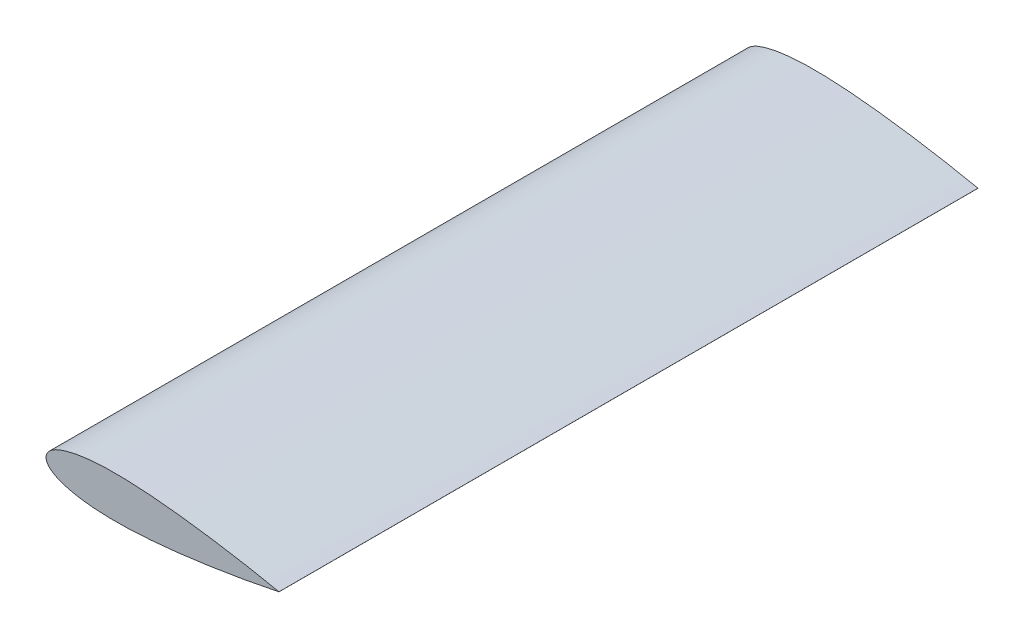
from build123d import *

# Parameters (mm, degrees)
BOSS_EXTRUDE1_DEPTH = 600


with BuildPart() as part:
    # Sketch2 → Boss-Extrude1 (new body)
    with BuildSketch(Plane.XY):
        with BuildLine():
            Line((200, 0.026021305), (200, -0.026021313))
            add(Edge.make_bspline(
                [(200, 0.026021305), (196.133660298, 0.824460007), (188.973100367, 2.314029776), (175.197231938, 4.95350612), (158.682087923, 7.864416996), (138.848303334, 10.963035098), (119.017582397, 13.652387002), (99.186590163, 15.851924276), (79.350823181, 17.41083287), (62.801573061, 17.964567123), (49.570059005, 17.74356646), (39.638389621, 17.155457266), (29.688048318, 16.020003739), (21.406431266, 14.43331701), (14.801094645, 12.546196453), (9.75689383, 10.639636938), (5.531834741, 8.343752603), (1.645401824, 5.168264306), (-1.073716587, 0), (1.645401824, -5.168264306), (5.53183474, -8.343752603), (9.756893829, -10.639636938), (14.801094645, -12.546196453), (21.406431266, -14.43331701), (29.688048318, -16.02000374), (39.63838962, -17.155457267), (49.570059005, -17.743566462), (62.801573061, -17.964567125), (79.350823181, -17.410832873), (99.186590162, -15.85192428), (119.017582396, -13.652387007), (138.848303334, -10.963035103), (158.682087923, -7.864417002), (175.197231937, -4.953506127), (188.973100367, -2.314029784), (196.133660298, -0.824460015), (200, -0.026021313)],
                knots=[-0.004189875, -0.004189875, -0.004189875, -0.004189875, 0.024603844, 0.049152359, 0.098108667, 0.146905312, 0.195554797, 0.244056277, 0.292409554, 0.340643731, 0.364754111, 0.3889056, 0.413178108, 0.437756239, 0.450304697, 0.463229879, 0.477067953, 0.485035559, 0.5, 0.514964441, 0.522932047, 0.536770121, 0.549695303, 0.562243761, 0.586821892, 0.6110944, 0.635245889, 0.659356269, 0.707590446, 0.755943723, 0.804445203, 0.853094688, 0.901891333, 0.950847641, 0.975396156, 1.004189875, 1.004189875, 1.004189875, 1.004189875], degree=3))
        make_face()
    extrude(amount=BOSS_EXTRUDE1_DEPTH)


solid = part.part
